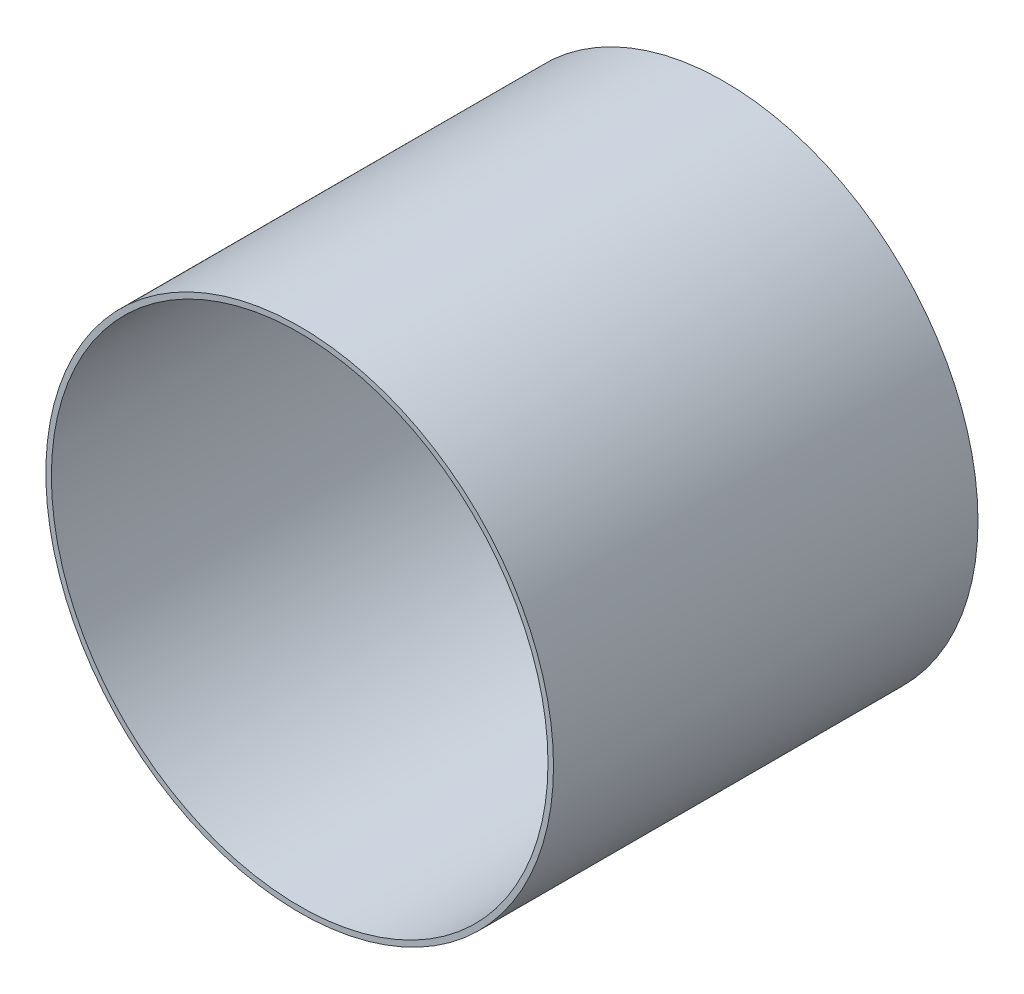
from build123d import *

# Parameters (mm, degrees)
SKETCH1_R           = 75.946
SKETCH1_R_2         = 74.295
BOSS_EXTRUDE1_DEPTH = 127


with BuildPart() as part:
    # Sketch1 → Boss-Extrude1 (new body)
    with BuildSketch(Plane.XY):
        Circle(SKETCH1_R)
        Circle(SKETCH1_R_2, mode=Mode.SUBTRACT)
    extrude(amount=BOSS_EXTRUDE1_DEPTH)


solid = part.part
